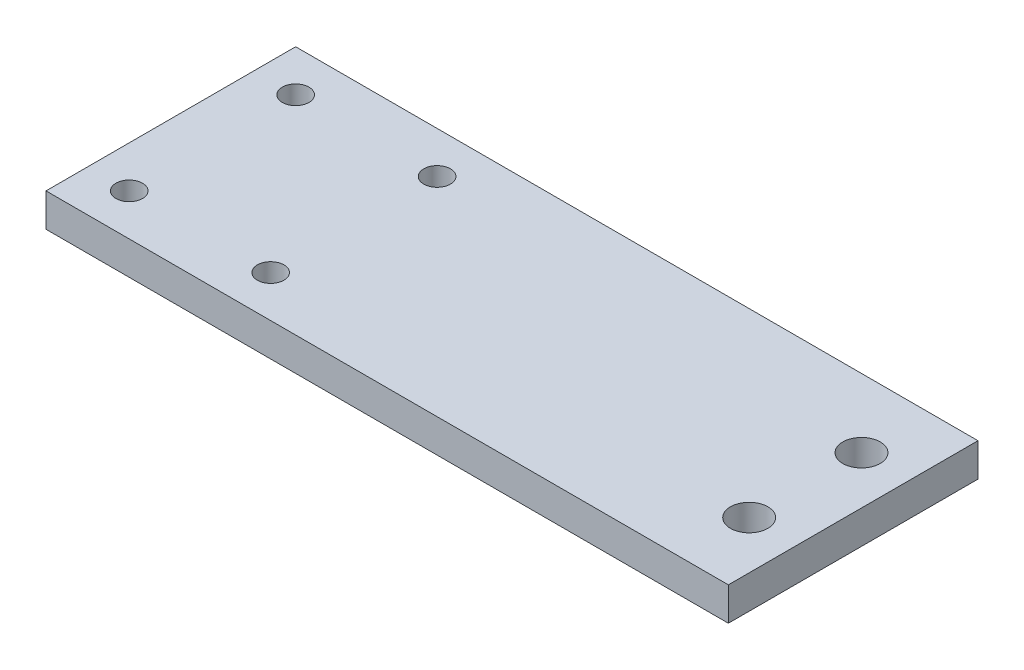
from build123d import *

# Parameters (mm, degrees)
SKETCH_1_W      = 82
SKETCH_1_H      = 30
SKETCH_1_R      = 1.6
SKETCH_1_R_2    = 2.25
EXTRUDE_1_DEPTH = 4


with BuildPart() as part:
    # 草图1 → 凸台-拉伸1 (new body)
    with BuildSketch(Plane(origin=(0, 0, 0), x_dir=(1, 0, 0), z_dir=(0, 1, 0))):
        with Locations((-1, 10)):
            Rectangle(SKETCH_1_W, SKETCH_1_H)
        with Locations((-20, 20)):
            Circle(SKETCH_1_R, mode=Mode.SUBTRACT)
        with Locations((-37, 20)):
            Circle(SKETCH_1_R, mode=Mode.SUBTRACT)
        with Locations((-20, 0)):
            Circle(SKETCH_1_R, mode=Mode.SUBTRACT)
        with Locations((-37, 0)):
            Circle(SKETCH_1_R, mode=Mode.SUBTRACT)
        with Locations((34.25, 16.75)):
            Circle(SKETCH_1_R_2, mode=Mode.SUBTRACT)
        with Locations((34.25, 3.25)):
            Circle(SKETCH_1_R_2, mode=Mode.SUBTRACT)
    extrude(amount=EXTRUDE_1_DEPTH)


solid = part.part
